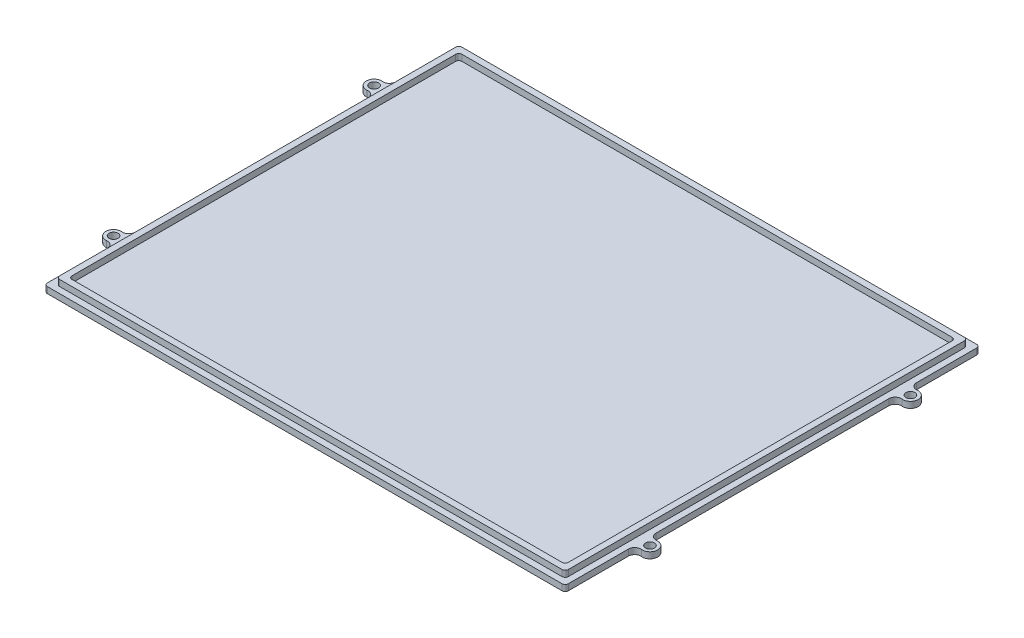
from build123d import *

# Parameters (mm, degrees)
EXTRUDE_1_DEPTH = 2
EXTRUDE_2_DEPTH = 2
SKETCH_3_R      = 1.45
EXTRUDE_5_DEPTH = 2


with BuildPart() as part:
    # 草图1 → 凸台-拉伸1 (new body)
    with BuildSketch(Plane(origin=(0, 0, 0), x_dir=(1, 0, 0), z_dir=(0, 1, 0))):
        with BuildLine():
            Line((-83.5, -67.25), (83.5, -67.25))
            ThreePointArc((83.5, -67.25), (84.207106781, -66.957106781), (84.5, -66.25))
            Line((84.5, -66.25), (84.5, 66.25))
            ThreePointArc((84.5, 66.25), (84.207106781, 66.957106781), (83.5, 67.25))
            Line((83.5, 67.25), (-83.5, 67.25))
            ThreePointArc((-83.5, 67.25), (-84.207106781, 66.957106781), (-84.5, 66.25))
            Line((-84.5, 66.25), (-84.5, -66.25))
            ThreePointArc((-84.5, -66.25), (-84.207106781, -66.957106781), (-83.5, -67.25))
        make_face()
    extrude(amount=EXTRUDE_1_DEPTH)

    # 草图2 → 凸台-拉伸2 (add)
    with BuildSketch(Plane(origin=(0, 2, 0), x_dir=(1, 0, 0), z_dir=(0, 1, 0))):
        with BuildLine():
            Line((-81.5, -65.25), (81.5, -65.25))
            ThreePointArc((81.5, -65.25), (82.207106781, -64.957106781), (82.5, -64.25))
            Line((82.5, -64.25), (82.5, 64.25))
            ThreePointArc((82.5, 64.25), (82.207106781, 64.957106781), (81.5, 65.25))
            Line((81.5, 65.25), (-81.5, 65.25))
            ThreePointArc((-81.5, 65.25), (-82.207106781, 64.957106781), (-82.5, 64.25))
            Line((-82.5, 64.25), (-82.5, -64.25))
            ThreePointArc((-82.5, -64.25), (-82.207106781, -64.957106781), (-81.5, -65.25))
        make_face()
        with BuildLine():
            Line((79.5, 63.25), (-79.5, 63.25))
            ThreePointArc((-79.5, 63.25), (-80.207106781, 62.957106781), (-80.5, 62.25))
            Line((-80.5, 62.25), (-80.5, -62.25))
            ThreePointArc((-80.5, -62.25), (-80.207106781, -62.957106781), (-79.5, -63.25))
            Line((-79.5, -63.25), (79.5, -63.25))
            ThreePointArc((79.5, -63.25), (80.207106781, -62.957106781), (80.5, -62.25))
            Line((80.5, -62.25), (80.5, 62.25))
            ThreePointArc((80.5, 62.25), (80.207106781, 62.957106781), (79.5, 63.25))
        make_face(mode=Mode.SUBTRACT)
    extrude(amount=EXTRUDE_2_DEPTH)

    # 草图3 → 凸台-拉伸5 (add)
    with BuildSketch(Plane.XZ):
        with BuildLine():
            Line((-84.5, 46.722135955), (-84.5, 37.777864045))
            ThreePointArc((-84.5, 37.777864045), (-85.166666667, 39.26857603), (-86.722222222, 39.765480025))
            ThreePointArc((-86.722222222, 39.765480025), (-89.5, 42.25), (-86.722222222, 44.734519975))
            ThreePointArc((-86.722222222, 44.734519975), (-85.166666667, 45.23142397), (-84.5, 46.722135955))
        make_face()
        with Locations((-87, 42.25)):
            Circle(SKETCH_3_R, mode=Mode.SUBTRACT)
        with BuildLine():
            Line((84.5, 46.722135955), (84.5, 37.777864045))
            ThreePointArc((84.5, 37.777864045), (85.166666667, 39.26857603), (86.722222222, 39.765480025))
            ThreePointArc((86.722222222, 39.765480025), (89.5, 42.25), (86.722222222, 44.734519975))
            ThreePointArc((86.722222222, 44.734519975), (85.166666667, 45.23142397), (84.5, 46.722135955))
        make_face()
        with Locations((87, 42.25)):
            Circle(SKETCH_3_R, mode=Mode.SUBTRACT)
        with BuildLine():
            Line((84.5, -46.722135955), (84.5, -37.777864045))
            ThreePointArc((84.5, -37.777864045), (85.166666667, -39.26857603), (86.722222222, -39.765480025))
            ThreePointArc((86.722222222, -39.765480025), (89.5, -42.25), (86.722222222, -44.734519975))
            ThreePointArc((86.722222222, -44.734519975), (85.166666667, -45.23142397), (84.5, -46.722135955))
        make_face()
        with Locations((87, -42.25)):
            Circle(SKETCH_3_R, mode=Mode.SUBTRACT)
        with BuildLine():
            Line((-84.5, -46.722135955), (-84.5, -37.777864045))
            ThreePointArc((-84.5, -37.777864045), (-85.166666667, -39.26857603), (-86.722222222, -39.765480025))
            ThreePointArc((-86.722222222, -39.765480025), (-89.5, -42.25), (-86.722222222, -44.734519975))
            ThreePointArc((-86.722222222, -44.734519975), (-85.166666667, -45.23142397), (-84.5, -46.722135955))
        make_face()
        with Locations((-87, -42.25)):
            Circle(SKETCH_3_R, mode=Mode.SUBTRACT)
    extrude(amount=-EXTRUDE_5_DEPTH)


solid = part.part
